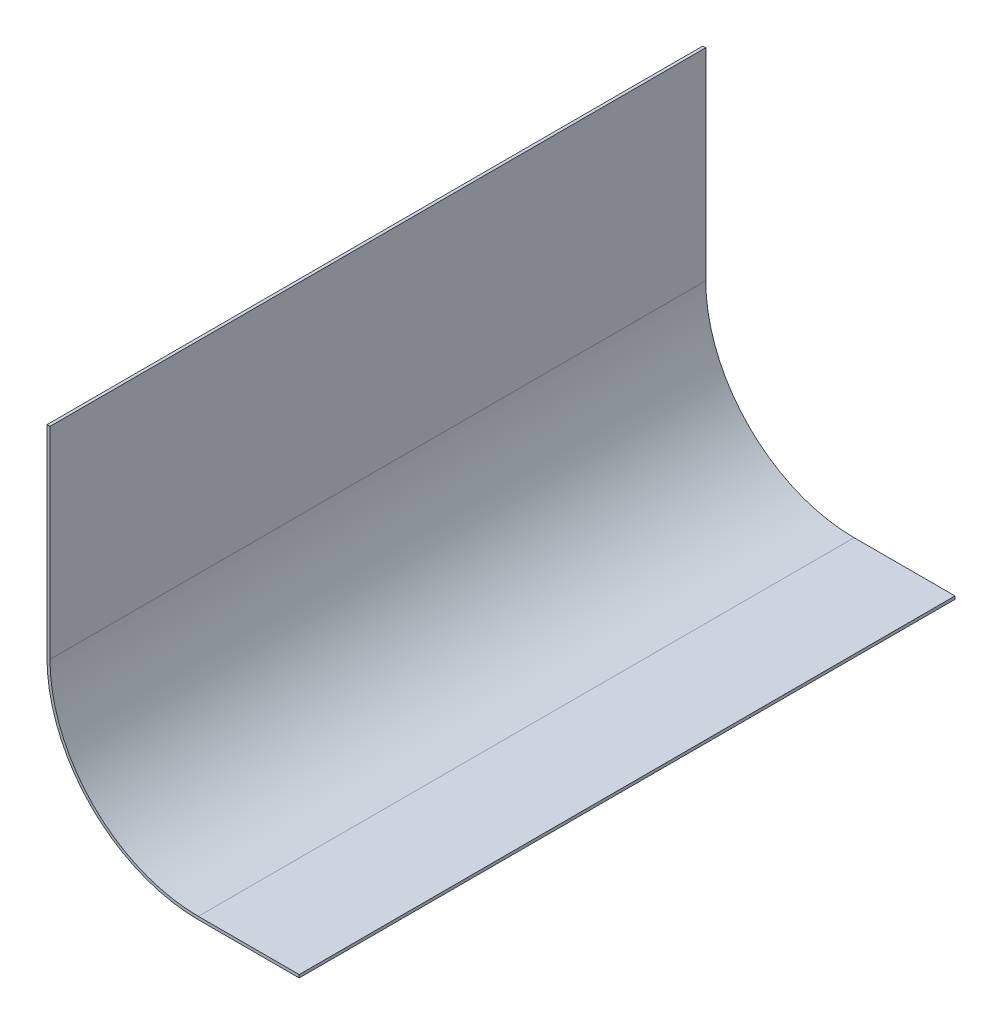
from build123d import *

# Parameters (mm, degrees)
EXTRUDE_THIN1_DEPTH = 165.1


with BuildPart() as part:
    # Sketch1 → Extrude-Thin1 (new body, symmetric)
    with BuildSketch(Plane.XY):
        with BuildLine():
            Line((-418.175, 990.6), (-468.975, 990.6))
            ThreePointArc((-468.975, 990.6), (-522.856536726, 1012.918463274), (-545.175, 1066.8))
            Line((-545.175, 1066.8), (-545.175, 1168.4))
            Line((-545.175, 1168.4), (-543.675, 1168.4))
            Line((-543.675, 1168.4), (-543.675, 1066.8))
            ThreePointArc((-543.675, 1066.8), (-521.795876555, 1013.979123445), (-468.975, 992.1))
            Line((-468.975, 992.1), (-418.175, 992.1))
            Line((-418.175, 992.1), (-418.175, 990.6))
        make_face()
    extrude(amount=EXTRUDE_THIN1_DEPTH, both=True)


solid = part.part
